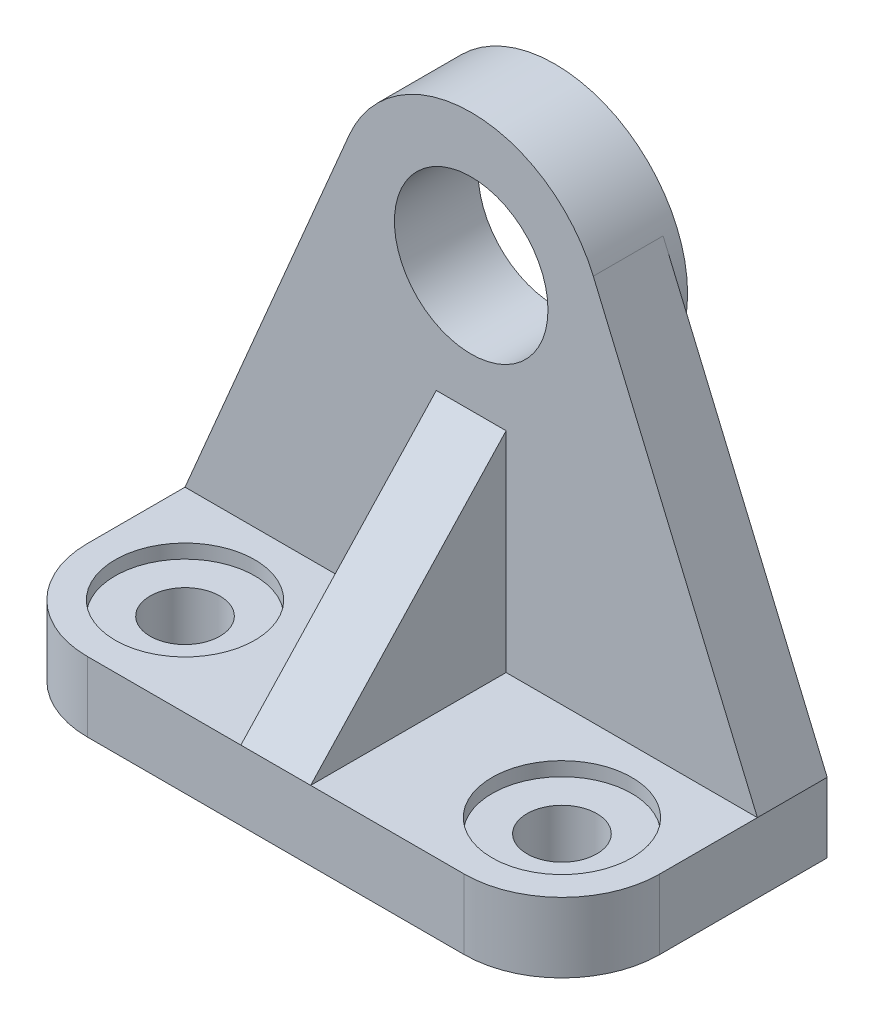
from build123d import *

# Parameters (mm, degrees)
EXTRUDE_1_DEPTH     = 41
SKETCH_2_R          = 11
CUT_EXTRUDE_1_DEPTH = 82
EXTRUDE_2_DEPTH     = 5
FILLET_1_R          = 14
CUT_EXTRUDE_2_REACH = 79
SKETCH_4_R          = 5
SKETCH_5_R          = 10
CUT_EXTRUDE_3_DEPTH = 2
SKETCH_6_R          = 19
SKETCH_6_R_2        = 11
EXTRUDE_3_DEPTH     = 2


with BuildPart() as part:
    # 스케치1 → 보스-돌출1 (new body, symmetric)
    with BuildSketch(Plane(origin=(0, 0, 0), x_dir=(0, 0, -1), z_dir=(1, 0, 0))):
        Polygon((0, 0), (38, 0), (38, 77), (28, 77), (28, 10), (0, 10), align=None)
    extrude(amount=EXTRUDE_1_DEPTH, both=True)

    # 스케치2 → 컷-돌출1 (cut)
    with BuildSketch(Plane.XY.offset(-28)):
        with BuildLine():
            Line((-41, 77), (-41, 10))
            Line((-41, 10), (-17.491366878, 65.419709208))
            ThreePointArc((-17.491366878, 65.419709208), (-10.488696893, 73.842576731), (0, 77))
            Line((0, 77), (-41, 77))
        make_face()
        with BuildLine():
            Line((41, 77), (0, 77))
            ThreePointArc((0, 77), (10.488696893, 73.842576731), (17.491366878, 65.419709208))
            Line((17.491366878, 65.419709208), (41, 10))
            Line((41, 10), (41, 77))
        make_face()
        with Locations((0, 58)):
            Circle(SKETCH_2_R)
    extrude(amount=-CUT_EXTRUDE_1_DEPTH, mode=Mode.SUBTRACT)

    # 스케치3 → 보스-돌출2 (add, symmetric)
    with BuildSketch(Plane(origin=(0, 0, 0), x_dir=(0, 0, -1), z_dir=(1, 0, 0))):
        Polygon((0, 10), (28, 10), (28, 40), align=None)
    extrude(amount=EXTRUDE_2_DEPTH, both=True)

    # 필렛1
    fillet_1_edges = [part.edges().sort_by_distance(p)[0] for p in [
        (41, 5, 0),
        (-41, 5, 0),
    ]]
    fillet(fillet_1_edges, radius=FILLET_1_R)

    # 스케치4 → 컷-돌출2 (cut, up to next)
    with BuildSketch(Plane(origin=(0, 0, 0), x_dir=(1, 0, 0), z_dir=(0, 1, 0)), mode=Mode.PRIVATE) as cut_extrude_2_sk1:
        with Locations(Location((-27, 14, 0), (0, 0, 90))):  # turned: the seam where the file's is
            Circle(SKETCH_4_R)
    cut_extrude_2_tool1 = extrude(cut_extrude_2_sk1.sketch, amount=CUT_EXTRUDE_2_REACH, mode=Mode.PRIVATE) & part.part
    add(cut_extrude_2_tool1.solids().sort_by_distance((-27, 0, -14))[0], mode=Mode.SUBTRACT)
    # 스케치4 → 컷-돌출2 (cut, up to next)
    with BuildSketch(Plane(origin=(0, 0, 0), x_dir=(1, 0, 0), z_dir=(0, 1, 0)), mode=Mode.PRIVATE) as cut_extrude_2_sk2:
        with Locations(Location((27, 14, 0), (0, 0, 90))):  # turned: the seam where the file's is
            Circle(SKETCH_4_R)
    cut_extrude_2_tool2 = extrude(cut_extrude_2_sk2.sketch, amount=CUT_EXTRUDE_2_REACH, mode=Mode.PRIVATE) & part.part
    add(cut_extrude_2_tool2.solids().sort_by_distance((27, 0, -14))[0], mode=Mode.SUBTRACT)

    # 스케치5 → 컷-돌출3 (cut)
    with BuildSketch(Plane(origin=(0, 10, 0), x_dir=(1, 0, 0), z_dir=(0, 1, 0))):
        with Locations(Location((-27, 14, 0), (0, 0, 270))):  # turned: the seam where the file's is
            Circle(SKETCH_5_R)
        with Locations(Location((27, 14, 0), (0, 0, 270))):  # turned: the seam where the file's is
            Circle(SKETCH_5_R)
    extrude(amount=-CUT_EXTRUDE_3_DEPTH, mode=Mode.SUBTRACT)

    # 스케치6 → 보스-돌출3 (add)
    with BuildSketch(Plane(origin=(0, 0, -38), x_dir=(-1, 0, 0), z_dir=(0, 0, -1))):
        with Locations(Location((0, 58, 0), (0, 0, 157.01370027))):  # turned: the seam where the file's is
            Circle(SKETCH_6_R)
        with Locations(Location((0, 58, 0), (0, 0, 180))):  # turned: the seam where the file's is
            Circle(SKETCH_6_R_2, mode=Mode.SUBTRACT)
    extrude(amount=EXTRUDE_3_DEPTH)


solid = part.part
